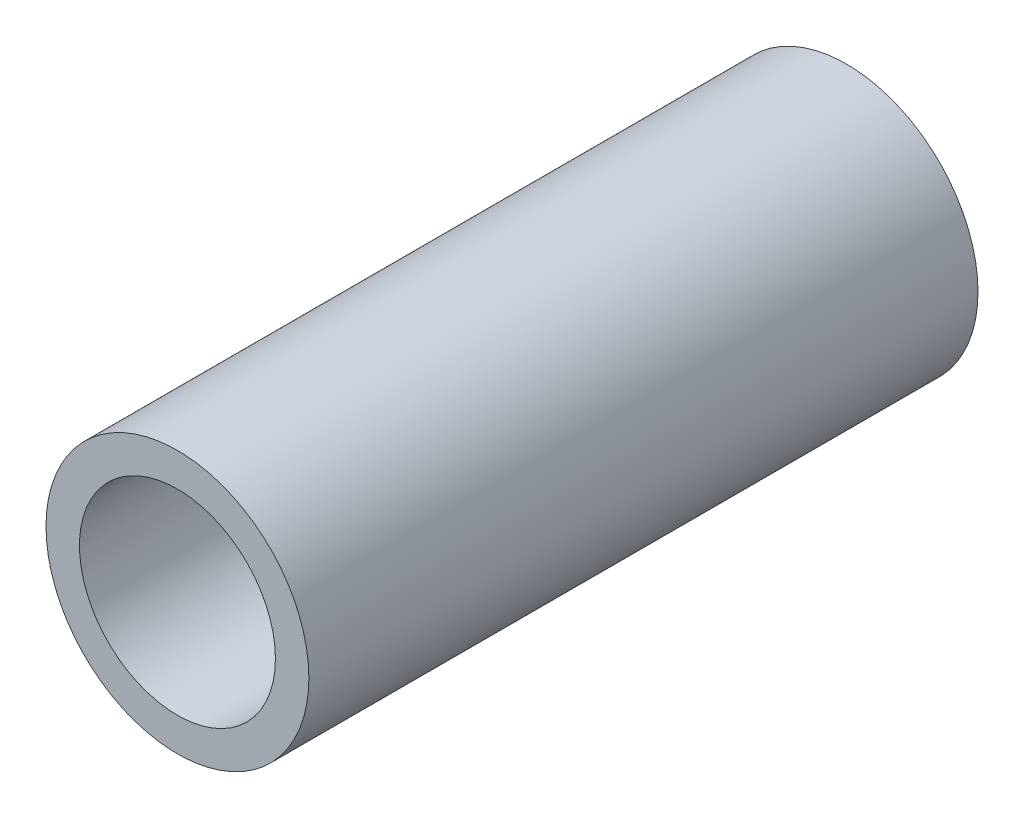
from build123d import *

# Parameters (mm, degrees)
SKETCH1_R           = 5.5
SKETCH1_R_2         = 4.1
BOSS_EXTRUDE1_DEPTH = 28


with BuildPart() as part:
    # Sketch1 → Boss-Extrude1 (new body)
    with BuildSketch(Plane.XY):
        Circle(SKETCH1_R)
        Circle(SKETCH1_R_2, mode=Mode.SUBTRACT)
    extrude(amount=BOSS_EXTRUDE1_DEPTH)


solid = part.part
